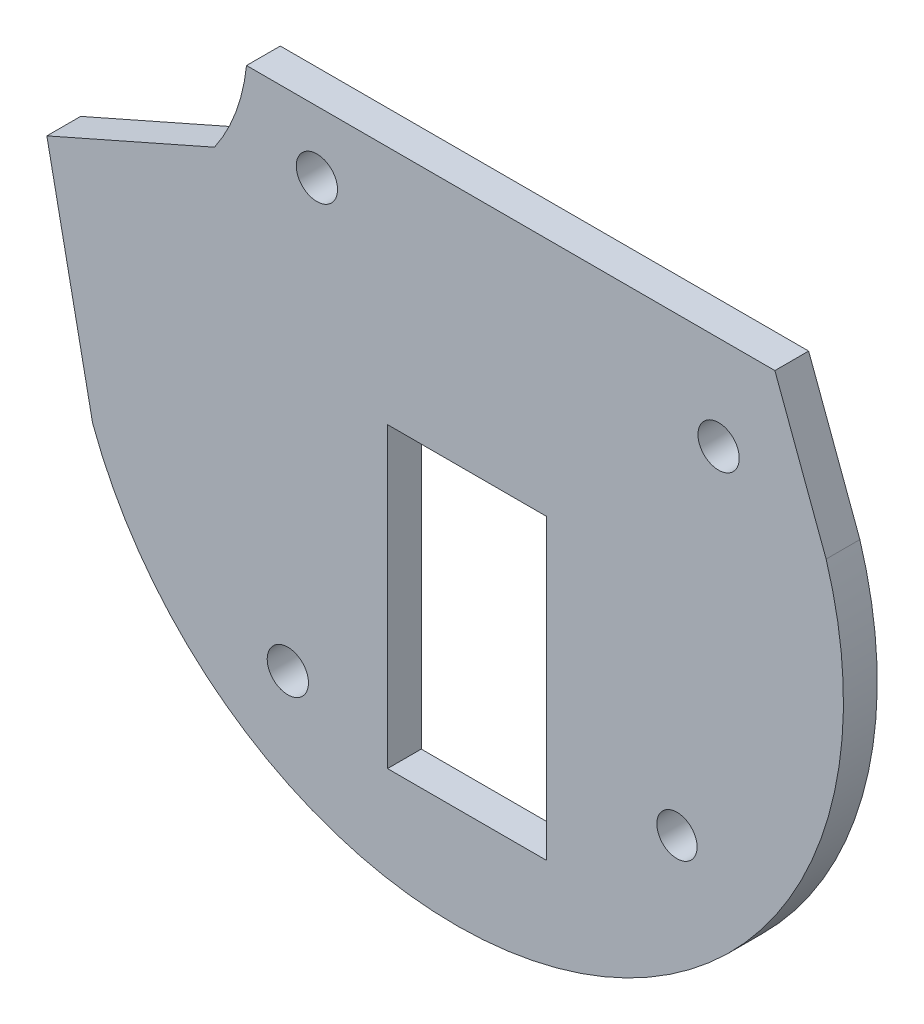
from build123d import *

# Parameters (mm, degrees)
SKETCH5_R      = 1.397
SKETCH5_R_2    = 1.362219034
EXTRUDE1_DEPTH = 2.286
SKETCH10_W     = 10.7696
SKETCH10_H     = 20.1676
EXTRUDE2_DEPTH = 2.286


with BuildPart() as part:
    # Sketch5 → Extrude1 (new body)
    with BuildSketch(Plane(origin=(0, 0, 0), x_dir=(-0.018375543, 0.999831155, 0), z_dir=(0, 0, -1))):
        with BuildLine():
            Line((33.80665155, 26.18621859), (34.46394605, -9.577814671))
            ThreePointArc((34.46394605, -9.577814671), (31.404055355, -10.348947358), (28.630167887, -11.853315998))
            Line((28.630167887, -11.853315998), (23.830153765, -23.292701447))
            Line((23.830153765, -23.292701447), (8.486225874, -20.477486777))
            ThreePointArc((8.486225874, -20.477486777), (-7.865336256, 12.262044577), (24.425706506, 29.482353943))
            Line((24.425706506, 29.482353943), (33.80665155, 26.18621859))
        make_face()
        with Locations((27.527734531, 22.260177192)):
            Circle(SKETCH5_R, mode=Mode.SUBTRACT)
        with Locations((30.179746314, -4.890797216)):
            Circle(SKETCH5_R, mode=Mode.SUBTRACT)
        with Locations((3.363138785, 18.996048152)):
            Circle(SKETCH5_R_2, mode=Mode.SUBTRACT)
        with Locations((0.317842079, -7.407837933)):
            Circle(SKETCH5_R, mode=Mode.SUBTRACT)
    extrude(amount=EXTRUDE1_DEPTH)

    # Sketch10 → Extrude2 (cut)
    with BuildSketch(Plane(origin=(0, 0, -2.286), x_dir=(-1, 0, 0), z_dir=(0, 0, -1))):
        with Locations((-4.719875056, 7.916929458)):
            Rectangle(SKETCH10_W, SKETCH10_H)
    extrude(amount=-EXTRUDE2_DEPTH, mode=Mode.SUBTRACT)


solid = part.part
